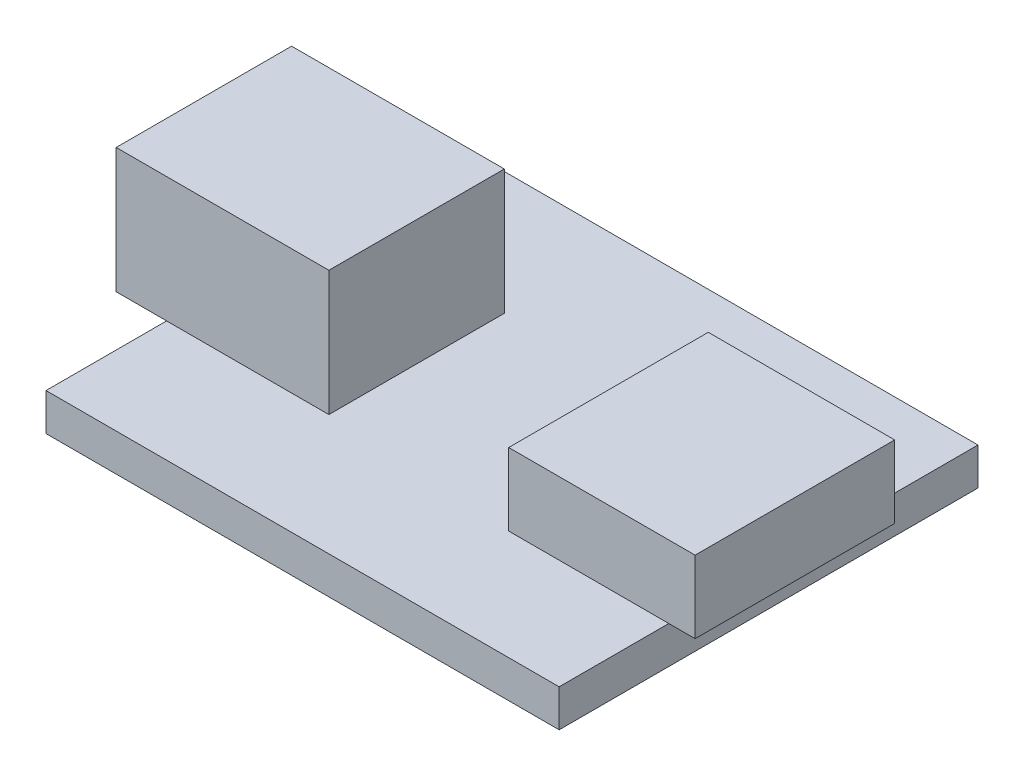
from build123d import *

# Parameters (mm, degrees)
SKETCH1_W           = 23.4
SKETCH1_H           = 19.1
BOSS_EXTRUDE1_DEPTH = 1.7
SKETCH2_W           = 7.3
SKETCH2_H           = 9.1
BOSS_EXTRUDE2_DEPTH = 3.3
SKETCH3_W           = 9.1
SKETCH3_H           = 3.3
BOSS_EXTRUDE3_DEPTH = 1.2
SKETCH4_W           = 7.4
SKETCH4_H           = 8
BOSS_EXTRUDE5_DEPTH = 5.7
SKETCH5_W           = 8
SKETCH5_H           = 5.7
BOSS_EXTRUDE6_DEPTH = 2.3


with BuildPart() as part:
    # Sketch1 → Boss-Extrude1 (new body)
    with BuildSketch(Plane(origin=(0, 0, 0), x_dir=(1, 0, 0), z_dir=(0, 1, 0))):
        Rectangle(SKETCH1_W, SKETCH1_H)
    extrude(amount=BOSS_EXTRUDE1_DEPTH)

    # Sketch2 → Boss-Extrude2 (add)
    with BuildSketch(Plane(origin=(0, 1.7, 0), x_dir=(1, 0, 0), z_dir=(0, 1, 0))):
        with Locations((8.05, 0)):
            Rectangle(SKETCH2_W, SKETCH2_H)
    extrude(amount=BOSS_EXTRUDE2_DEPTH)

    # Sketch3 → Boss-Extrude3 (add)
    with BuildSketch(Plane(origin=(11.7, 0, 0), x_dir=(0, 0, -1), z_dir=(1, 0, 0))):
        with Locations((0, 3.35)):
            Rectangle(SKETCH3_W, SKETCH3_H)
    extrude(amount=BOSS_EXTRUDE3_DEPTH)

    # Sketch4 → Boss-Extrude5 (add)
    with BuildSketch(Plane(origin=(0, 1.7, 0), x_dir=(1, 0, 0), z_dir=(0, 1, 0))):
        with Locations((-8, -0.05)):
            Rectangle(SKETCH4_W, SKETCH4_H)
    extrude(amount=BOSS_EXTRUDE5_DEPTH)

    # Sketch5 → Boss-Extrude6 (add)
    with BuildSketch(Plane.ZY.offset(11.7)):
        with Locations((0.05, 4.55)):
            Rectangle(SKETCH5_W, SKETCH5_H)
    extrude(amount=BOSS_EXTRUDE6_DEPTH)


solid = part.part
